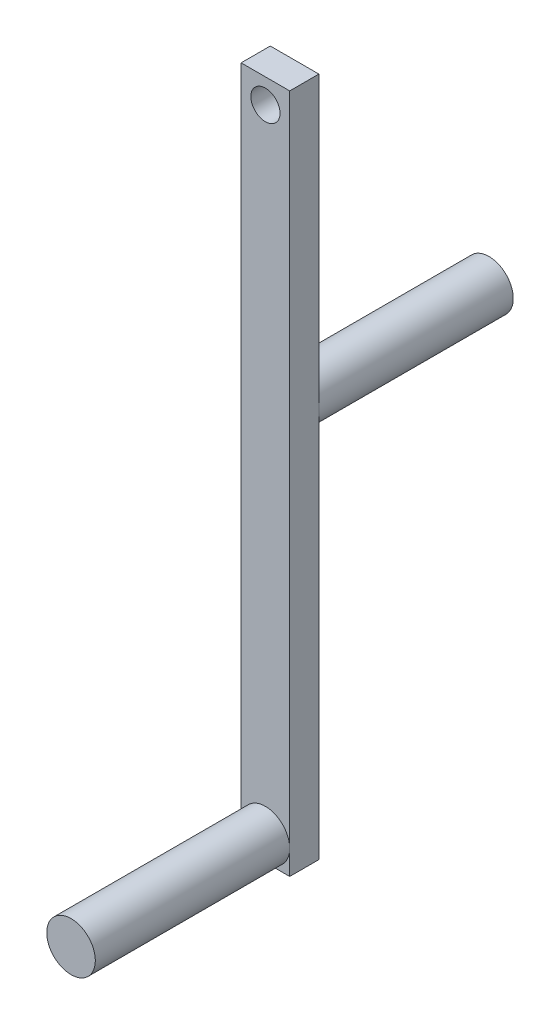
from build123d import *

# Parameters (mm, degrees)
SKETCH1_W           = 5
SKETCH1_H           = 70
BOSS_EXTRUDE1_DEPTH = 3
SKETCH2_R           = 2.5
BOSS_EXTRUDE2_DEPTH = 20
SKETCH3_R           = 2.5
BOSS_EXTRUDE3_DEPTH = 20
SKETCH4_R           = 1.5
CUT_EXTRUDE1_DEPTH  = 20


with BuildPart() as part:
    # Sketch1 → Boss-Extrude1 (new body)
    with BuildSketch(Plane.XY):
        with Locations((2.5, 35)):
            Rectangle(SKETCH1_W, SKETCH1_H)
    extrude(amount=BOSS_EXTRUDE1_DEPTH)

    # Sketch2 → Boss-Extrude2 (add)
    with BuildSketch(Plane.XY.offset(3)):
        with Locations((2.5, 2.5)):
            Circle(SKETCH2_R)
    extrude(amount=BOSS_EXTRUDE2_DEPTH)

    # Sketch3 → Boss-Extrude3 (add)
    with BuildSketch(Plane(origin=(0, 0, 0), x_dir=(-1, 0, 0), z_dir=(0, 0, -1))):
        with Locations((-2.5, 40)):
            Circle(SKETCH3_R)
    extrude(amount=BOSS_EXTRUDE3_DEPTH)

    # Sketch4 → Cut-Extrude1 (cut)
    with BuildSketch(Plane(origin=(0, 0, 0), x_dir=(-1, 0, 0), z_dir=(0, 0, -1))):
        with Locations((-2.5, 67.5)):
            Circle(SKETCH4_R)
    extrude(amount=-CUT_EXTRUDE1_DEPTH, mode=Mode.SUBTRACT)


solid = part.part
